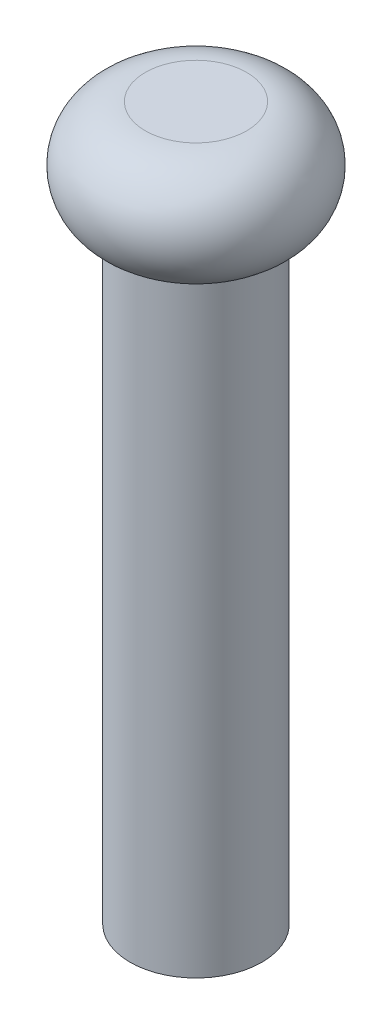
from build123d import *


with BuildPart() as part:
    # Sketch1 → Revolve1 (revolve)
    with BuildSketch(Plane.XY):
        with BuildLine():
            Line((0, 0), (1.25, 0))
            Line((1.25, 0), (1.25, 11.5))
            Line((1.25, 11.5), (1.36, 11.5))
            ThreePointArc((1.36, 11.5), (1.979803903, 12.663960781), (0.96, 13.5))
            Line((0.96, 13.5), (0, 13.5))
            Line((0, 13.5), (0, 0))
        make_face()
    revolve(axis=Axis((0, -100.325704338, 0), (0, 1, 0)))


solid = part.part
